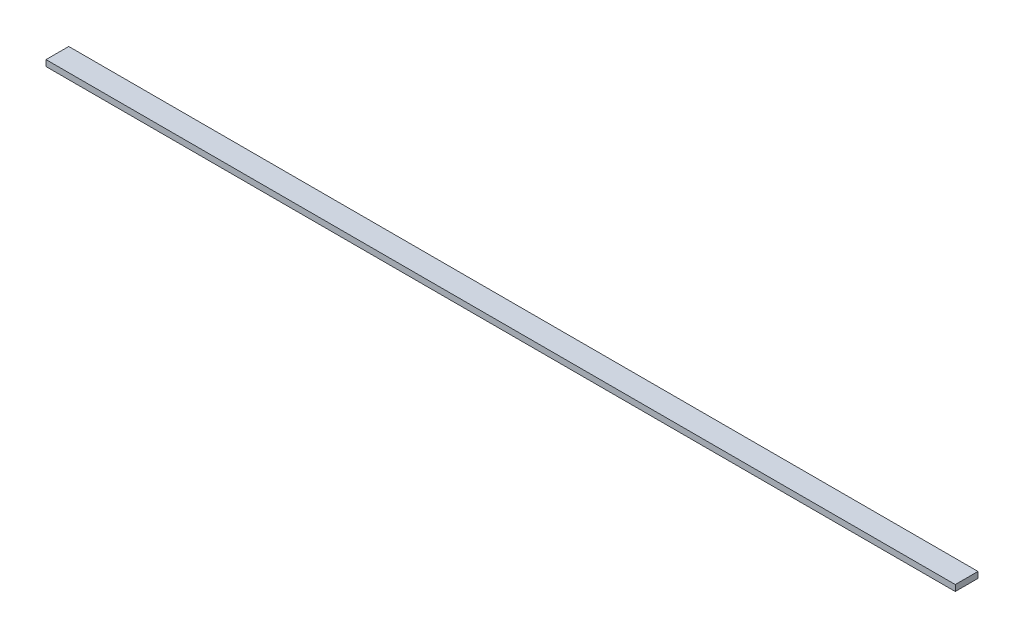
from build123d import *

# Parameters (mm, degrees)
SKETCH_1_W      = 1200
SKETCH_1_H      = 30
EXTRUDE_1_DEPTH = 8


with BuildPart() as part:
    # Эскиз1 → Бобышка-Вытянуть1 (new body)
    with BuildSketch(Plane(origin=(0, 0, 0), x_dir=(1, 0, 0), z_dir=(0, 1, 0))):
        Rectangle(SKETCH_1_W, SKETCH_1_H)
    extrude(amount=EXTRUDE_1_DEPTH)


solid = part.part
